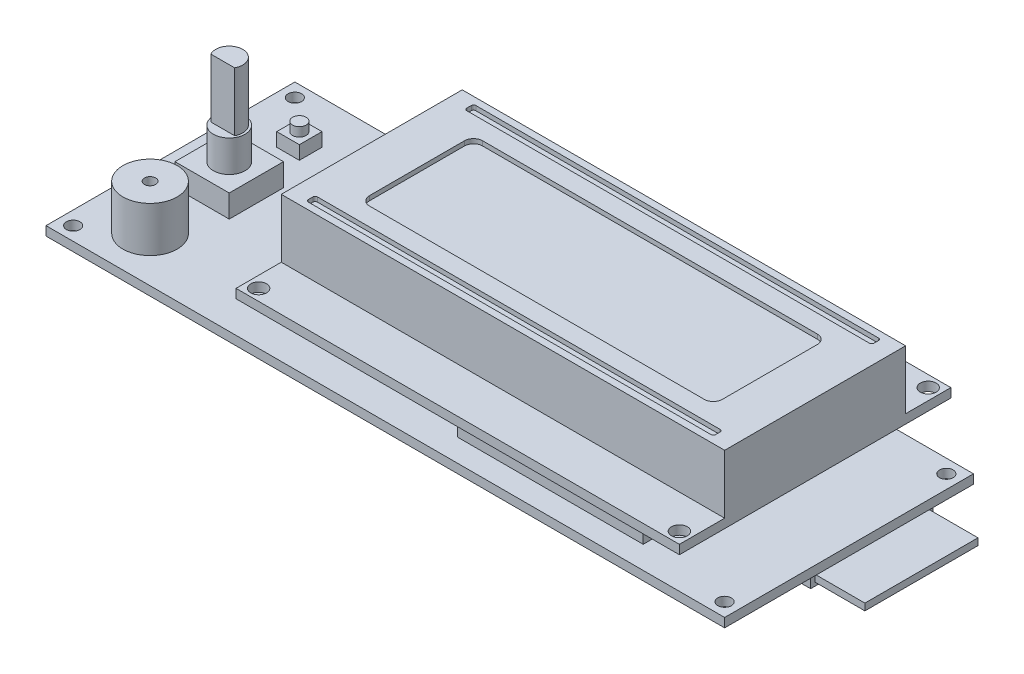
from build123d import *

# Parameters (mm, degrees)
SKETCH1_W           = 150
SKETCH1_H           = 55
SKETCH1_R           = 1.5
BOSS_EXTRUDE1_DEPTH = 2
SKETCH2_R           = 6
BOSS_EXTRUDE2_DEPTH = 10
SKETCH3_W           = 12
SKETCH3_H           = 12
BOSS_EXTRUDE3_DEPTH = 25
SKETCH4_W           = 5
SKETCH4_H           = 5
SKETCH4_W_2         = 41
SKETCH4_H_2         = 3
BOSS_EXTRUDE4_DEPTH = 5
SKETCH5_W           = 41
SKETCH5_H           = 3
SKETCH5_W_2         = 5
SKETCH5_H_2         = 5
SKETCH5_R           = 1.5
CUT_EXTRUDE1_DEPTH  = 2
SKETCH6_W           = 12
SKETCH6_H           = 12
CUT_EXTRUDE2_DEPTH  = 13
SKETCH7_W           = 12
SKETCH7_H           = 12
SKETCH7_R           = 3.5
CUT_EXTRUDE3_DEPTH  = 7
SKETCH8_R           = 1.25
CUT_EXTRUDE4_DEPTH  = 5
BOSS_EXTRUDE5_DEPTH = 3
SKETCH10_W          = 25
SKETCH10_H          = 1.5
CUT_EXTRUDE5_DEPTH  = 18
SKETCH11_W          = 98
SKETCH11_H          = 60
SKETCH11_R          = 1.75
BOSS_EXTRUDE6_DEPTH = 2
SKETCH12_W          = 98
SKETCH12_H          = 40
BOSS_EXTRUDE7_DEPTH = 13
CUT_EXTRUDE6_DEPTH  = 1
SKETCH14_W          = 25
SKETCH14_H          = 1.5
BOSS_EXTRUDE8_DEPTH = 29


with BuildPart() as part:
    # Sketch1 → Boss-Extrude1 (new body)
    with BuildSketch(Plane(origin=(0, 0, 0), x_dir=(1, 0, 0), z_dir=(0, 1, 0))):
        with Locations((75, 27.5)):
            Rectangle(SKETCH1_W, SKETCH1_H)
        with Locations((3, 52)):
            Circle(SKETCH1_R, mode=Mode.SUBTRACT)
        with Locations((147, 52)):
            Circle(SKETCH1_R, mode=Mode.SUBTRACT)
        with Locations((147, 3)):
            Circle(SKETCH1_R, mode=Mode.SUBTRACT)
        with Locations((3, 3)):
            Circle(SKETCH1_R, mode=Mode.SUBTRACT)
    extrude(amount=BOSS_EXTRUDE1_DEPTH)

    # Sketch2 → Boss-Extrude2 (add)
    with BuildSketch(Plane(origin=(0, 2, 0), x_dir=(1, 0, 0), z_dir=(0, 1, 0))):
        with Locations((13, 10)):
            Circle(SKETCH2_R)
    extrude(amount=BOSS_EXTRUDE2_DEPTH)

    # Sketch3 → Boss-Extrude3 (add)
    with BuildSketch(Plane(origin=(0, 2, 0), x_dir=(1, 0, 0), z_dir=(0, 1, 0))):
        with Locations((13, 27.5)):
            Rectangle(SKETCH3_W, SKETCH3_H)
    extrude(amount=BOSS_EXTRUDE3_DEPTH)

    # Sketch4 → Boss-Extrude4 (add)
    with BuildSketch(Plane(origin=(0, 2, 0), x_dir=(1, 0, 0), z_dir=(0, 1, 0))):
        with Locations((13, 43)):
            Rectangle(SKETCH4_W, SKETCH4_H)
        with Locations((106.5, 6.5)):
            Rectangle(SKETCH4_W_2, SKETCH4_H_2)
    extrude(amount=BOSS_EXTRUDE4_DEPTH)

    # Sketch5 → Cut-Extrude1 (cut)
    with BuildSketch(Plane(origin=(0, 7, 0), x_dir=(1, 0, 0), z_dir=(0, 1, 0))):
        with Locations((106.5, 6.5)):
            Rectangle(SKETCH5_W, SKETCH5_H)
        with Locations((13, 43)):
            Rectangle(SKETCH5_W_2, SKETCH5_H_2)
        with Locations((13, 43)):
            Circle(SKETCH5_R, mode=Mode.SUBTRACT)
    extrude(amount=-CUT_EXTRUDE1_DEPTH, mode=Mode.SUBTRACT)

    # Sketch6 → Cut-Extrude2 (cut)
    with BuildSketch(Plane(origin=(0, 27, 0), x_dir=(1, 0, 0), z_dir=(0, 1, 0))):
        with Locations((13, 27.5)):
            Rectangle(SKETCH6_W, SKETCH6_H)
        with BuildLine():
            Line((10.370614338, 26.055586264), (15.629385662, 26.055586264))
            ThreePointArc((15.629385662, 26.055586264), (13, 30.5), (10.370614338, 26.055586264))
        make_face(mode=Mode.SUBTRACT)
    extrude(amount=-CUT_EXTRUDE2_DEPTH, mode=Mode.SUBTRACT)

    # Sketch7 → Cut-Extrude3 (cut)
    with BuildSketch(Plane(origin=(0, 14, 0), x_dir=(1, 0, 0), z_dir=(0, 1, 0))):
        with Locations((13, 27.5)):
            Rectangle(SKETCH7_W, SKETCH7_H)
        with Locations((13, 27.5)):
            Circle(SKETCH7_R, mode=Mode.SUBTRACT)
    extrude(amount=-CUT_EXTRUDE3_DEPTH, mode=Mode.SUBTRACT)

    # Sketch8 → Cut-Extrude4 (cut)
    with BuildSketch(Plane(origin=(0, 12, 0), x_dir=(1, 0, 0), z_dir=(0, 1, 0))):
        with Locations((13, 10)):
            Circle(SKETCH8_R)
    extrude(amount=-CUT_EXTRUDE4_DEPTH, mode=Mode.SUBTRACT)

    # Sketch9 → Boss-Extrude5 (add)
    with BuildSketch(Plane.XZ):
        Polygon((149, -20), (131, -20), (129, -22), (124, -22), (124, -47), (149, -47), align=None)
    extrude(amount=BOSS_EXTRUDE5_DEPTH)

    # Sketch10 → Cut-Extrude5 (cut)
    with BuildSketch(Plane(origin=(149, 0, 0), x_dir=(0, 0, -1), z_dir=(1, 0, 0))):
        with Locations((33.5, -1.5)):
            Rectangle(SKETCH10_W, SKETCH10_H)
    extrude(amount=-CUT_EXTRUDE5_DEPTH, mode=Mode.SUBTRACT)

    # Sketch11 → Boss-Extrude6 (add)
    with BuildSketch(Plane(origin=(0, 5, 0), x_dir=(1, 0, 0), z_dir=(0, 1, 0))):
        with Locations((87, 34)):
            Rectangle(SKETCH11_W, SKETCH11_H)
        with Locations((40.5, 61.5)):
            Circle(SKETCH11_R, mode=Mode.SUBTRACT)
        with Locations((133.5, 61.5)):
            Circle(SKETCH11_R, mode=Mode.SUBTRACT)
        with Locations((133.5, 6.5)):
            Circle(SKETCH11_R, mode=Mode.SUBTRACT)
        with Locations((40.5, 6.5)):
            Circle(SKETCH11_R, mode=Mode.SUBTRACT)
    extrude(amount=BOSS_EXTRUDE6_DEPTH)

    # Sketch12 → Boss-Extrude7 (add)
    with BuildSketch(Plane(origin=(0, 7, 0), x_dir=(1, 0, 0), z_dir=(0, 1, 0))):
        with Locations((87, 34)):
            Rectangle(SKETCH12_W, SKETCH12_H)
    extrude(amount=BOSS_EXTRUDE7_DEPTH)

    # Sketch13 → Cut-Extrude6 (cut)
    with BuildSketch(Plane(origin=(0, 20, 0), x_dir=(1, 0, 0), z_dir=(0, 1, 0))):
        with BuildLine():
            Line((50, 46.5), (124, 46.5))
            ThreePointArc((124, 46.5), (125.414213562, 45.914213562), (126, 44.5))
            Line((126, 44.5), (126, 23.5))
            ThreePointArc((126, 23.5), (125.414213562, 22.085786438), (124, 21.5))
            Line((124, 21.5), (50, 21.5))
            ThreePointArc((50, 21.5), (48.585786438, 22.085786438), (48, 23.5))
            Line((48, 23.5), (48, 44.5))
            ThreePointArc((48, 44.5), (48.585786438, 45.914213562), (50, 46.5))
        make_face()
        with BuildLine():
            Line((42.5, 52.5), (131.5, 52.5))
            ThreePointArc((131.5, 52.5), (131.853553391, 52.353553391), (132, 52))
            Line((132, 52), (132, 51))
            ThreePointArc((132, 51), (131.853553391, 50.646446609), (131.5, 50.5))
            Line((131.5, 50.5), (42.5, 50.5))
            ThreePointArc((42.5, 50.5), (42.146446609, 50.646446609), (42, 51))
            Line((42, 51), (42, 52))
            ThreePointArc((42, 52), (42.146446609, 52.353553391), (42.5, 52.5))
        make_face()
        with BuildLine():
            Line((132, 16), (132, 17))
            ThreePointArc((132, 17), (131.853553391, 17.353553391), (131.5, 17.5))
            Line((131.5, 17.5), (42.5, 17.5))
            ThreePointArc((42.5, 17.5), (42.146446609, 17.353553391), (42, 17))
            Line((42, 17), (42, 16))
            ThreePointArc((42, 16), (42.146446609, 15.646446609), (42.5, 15.5))
            Line((42.5, 15.5), (131.5, 15.5))
            ThreePointArc((131.5, 15.5), (131.853553391, 15.646446609), (132, 16))
        make_face()
    extrude(amount=-CUT_EXTRUDE6_DEPTH, mode=Mode.SUBTRACT)

    # Sketch14 → Boss-Extrude8 (add)
    with BuildSketch(Plane(origin=(131, 0, 0), x_dir=(0, 0, -1), z_dir=(1, 0, 0))):
        with Locations((33.5, -1.5)):
            Rectangle(SKETCH14_W, SKETCH14_H)
    extrude(amount=BOSS_EXTRUDE8_DEPTH)


solid = part.part
